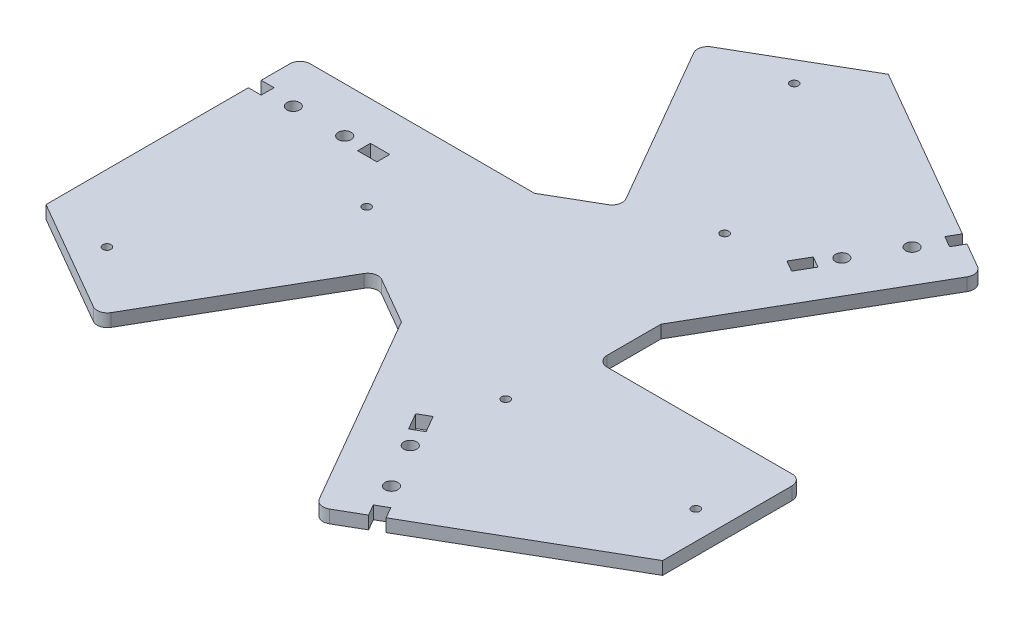
from build123d import *

# Parameters (mm, degrees)
SKETCH1_R           = 1.016
SKETCH1_R_2         = 1.5875
SKETCH1_W           = 4.7625
SKETCH1_H           = 3.175
BOSS_EXTRUDE2_DEPTH = 3.175


with BuildPart() as part:
    # Sketch1 → Boss-Extrude2 (new body)
    with BuildSketch(Plane(origin=(0, 0, 0), x_dir=(1, 0, 0), z_dir=(0, 1, 0))):
        with BuildLine():
            Line((-18.264134833, 18.784590512), (-73.66, 18.784590512))
            ThreePointArc((-73.66, 18.784590512), (-75.456051224, 18.040641736), (-76.2, 16.244590512))
            Line((-76.2, 16.244590512), (-76.2, 9.196090512))
            Line((-76.2, 9.196090512), (-73.025, 9.196090512))
            Line((-73.025, 9.196090512), (-73.025, 6.021090512))
            Line((-73.025, 6.021090512), (-76.2, 6.021090512))
            Line((-76.2, 6.021090512), (-76.2, -43.994090512))
            Line((-76.2, -43.994090512), (-48.493603884, -59.990385768))
            ThreePointArc((-48.493603884, -59.990385768), (-46.566203509, -60.244132842), (-45.023899358, -59.060681243))
            Line((-45.023899358, -59.060681243), (-22.163899358, -19.465999782))
            ThreePointArc((-22.163899358, -19.465999782), (-20.621595207, -18.282548183), (-18.694194832, -18.536295256))
            Line((-18.694194832, -18.536295256), (-7.155626979, -25.198090512))
            Line((-7.155626979, -25.198090512), (20.55218651, -73.189431243))
            ThreePointArc((20.55218651, -73.189431243), (22.094490662, -74.372882842), (24.021891036, -74.119135768))
            Line((24.021891036, -74.119135768), (30.126071095, -70.594885768))
            Line((30.126071095, -70.594885768), (28.538571095, -67.845255111))
            Line((28.538571095, -67.845255111), (31.288201752, -66.257755111))
            Line((31.288201752, -66.257755111), (32.875701752, -69.007385768))
            Line((32.875701752, -69.007385768), (76.2, -43.994090512))
            Line((76.2, -43.994090512), (76.2, -12.0015))
            ThreePointArc((76.2, -12.0015), (75.456051224, -10.205448776), (73.66, -9.4615))
            Line((73.66, -9.4615), (27.94, -9.4615))
            ThreePointArc((27.94, -9.4615), (26.143948776, -8.717551224), (25.4, -6.9215))
            Line((25.4, -6.9215), (25.4, 6.4135))
            Line((25.4, 6.4135), (53.097932583, 54.387726499))
            ThreePointArc((53.097932583, 54.387726499), (53.351679656, 56.315126873), (52.168228058, 57.857431024))
            Line((52.168228058, 57.857431024), (46.064047999, 61.381681024))
            Line((46.064047999, 61.381681024), (44.476547999, 58.632050367))
            Line((44.476547999, 58.632050367), (41.726917342, 60.219550367))
            Line((41.726917342, 60.219550367), (43.314417342, 62.969181024))
            Line((43.314417342, 62.969181024), (-0.009880906, 87.982476281))
            Line((-0.009880906, 87.982476281), (-27.706396116, 71.991885768))
            ThreePointArc((-27.706396116, 71.991885768), (-28.889847715, 70.449581617), (-28.636100642, 68.522181243))
            Line((-28.636100642, 68.522181243), (-5.776100642, 28.927499782))
            ThreePointArc((-5.776100642, 28.927499782), (-5.522353569, 27.000099407), (-6.705805168, 25.457795256))
            Line((-6.705805168, 25.457795256), (-18.264134833, 18.784590512))
        make_face()
        with Locations((69.2404, -28.829)):
            Circle(SKETCH1_R, mode=Mode.SUBTRACT)
        with Locations((-59.586846366, -45.549445368)):
            Circle(SKETCH1_R, mode=Mode.SUBTRACT)
        with Locations((-9.653553634, 74.378445368)):
            Circle(SKETCH1_R, mode=Mode.SUBTRACT)
        with Locations((22.2504, -28.829)):
            Circle(SKETCH1_R, mode=Mode.SUBTRACT)
        with Locations((-36.091846366, -4.854911644)):
            Circle(SKETCH1_R, mode=Mode.SUBTRACT)
        with Locations((13.841446366, 33.683911644)):
            Circle(SKETCH1_R, mode=Mode.SUBTRACT)
        with Locations((26.738386423, -61.552243797)):
            Circle(SKETCH1_R_2, mode=Mode.SUBTRACT)
        with Locations((20.388386423, -50.553721169)):
            Circle(SKETCH1_R_2, mode=Mode.SUBTRACT)
        with Locations((-53.975, 7.608590512)):
            Circle(SKETCH1_R_2, mode=Mode.SUBTRACT)
        with Locations((-66.675, 7.608590512)):
            Circle(SKETCH1_R_2, mode=Mode.SUBTRACT)
        with Locations((33.576732671, 42.928016425)):
            Circle(SKETCH1_R_2, mode=Mode.SUBTRACT)
        with Locations((39.926732671, 53.926539053)):
            Circle(SKETCH1_R_2, mode=Mode.SUBTRACT)
        Polygon((14.251071095, -43.098579198), (16.632321095, -47.223025184), (19.381951752, -45.635525184), (17.000701752, -41.511079198), align=None, mode=Mode.SUBTRACT)
        with Locations((-46.83125, 7.62)):
            Rectangle(SKETCH1_W, SKETCH1_H, mode=Mode.SUBTRACT)
        Polygon((29.830548248, 39.603025184), (27.449298248, 35.478579198), (30.198928905, 33.891079198), (32.580178905, 38.015525184), align=None, mode=Mode.SUBTRACT)
    extrude(amount=BOSS_EXTRUDE2_DEPTH)


solid = part.part
